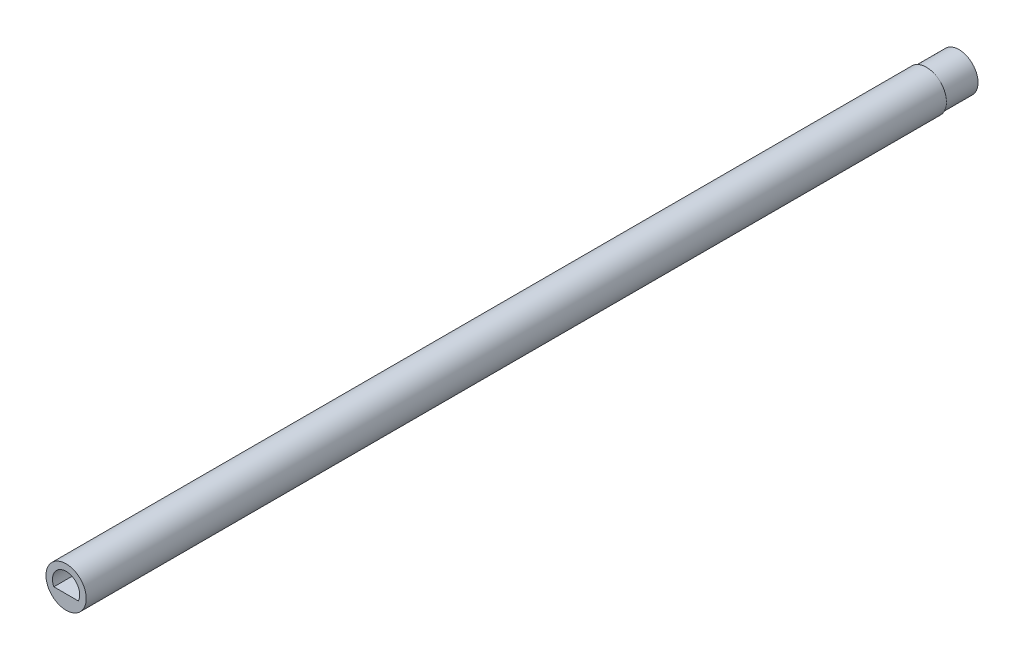
from build123d import *

# Parameters (mm, degrees)
SKETCH1_R           = 3.7
BOSS_EXTRUDE1_DEPTH = 158
SKETCH2_R           = 3.5
BOSS_EXTRUDE2_DEPTH = 6
CUT_EXTRUDE1_DEPTH  = 10


with BuildPart() as part:
    # Sketch1 → Boss-Extrude1 (new body)
    with BuildSketch(Plane.XY):
        Circle(SKETCH1_R)
    extrude(amount=BOSS_EXTRUDE1_DEPTH)

    # Sketch2 → Boss-Extrude2 (add)
    with BuildSketch(Plane(origin=(0, 0, 0), x_dir=(-1, 0, 0), z_dir=(0, 0, -1))):
        Circle(SKETCH2_R)
    extrude(amount=BOSS_EXTRUDE2_DEPTH)

    # Sketch4 → Cut-Extrude1 (cut)
    with BuildSketch(Plane.XY.offset(158)):
        with BuildLine():
            Line((-2.25, -1.089724736), (2.25, -1.089724736))
            ThreePointArc((2.25, -1.089724736), (0, 2.5), (-2.25, -1.089724736))
        make_face()
    extrude(amount=-CUT_EXTRUDE1_DEPTH, mode=Mode.SUBTRACT)


solid = part.part
